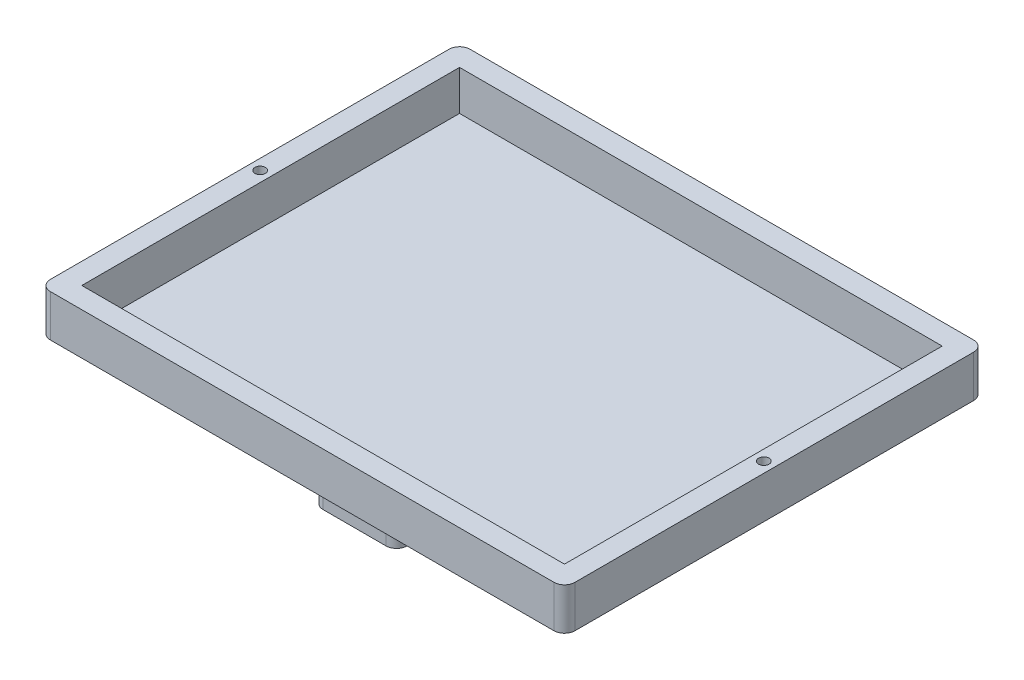
from build123d import *

# Parameters (mm, degrees)
SKETCH3_W               = 70
SKETCH3_H               = 60
BOSS_EXTRUDE1_DEPTH     = 20
BOSS_EXTRUDE2_DEPTH     = 20
SKETCH5_R               = 0.75
CUT_EXTRUDE1_DEPTH      = 119.321595662
SKETCH7_R               = 0.75
CUT_EXTRUDE2_DEPTH      = 119.321595662
LPATTERN2_COUNT         = 3
LPATTERN2_PITCH         = 2
LPATTERN3_COUNT         = 3
LPATTERN3_PITCH         = 2
SKETCH8_W               = 250
SKETCH8_H               = 200
BOSS_EXTRUDE3_DEPTH     = 20
SKETCH9_W               = 230
SKETCH9_H               = 180
CUT_EXTRUDE3_DEPTH      = 19
SKETCH10_W              = 40
SKETCH10_H              = 40
BOSS_EXTRUDE4_DEPTH     = 30
SKETCH11_W              = 34
SKETCH11_H              = 34
CUT_EXTRUDE4_DEPTH      = 28.5
SKETCH19_W              = 5
SKETCH19_H              = 5
BOSS_EXTRUDE5_DEPTH     = 10
MIRROR2_COPY_1_SKETCH_W = 5
MIRROR2_COPY_1_SKETCH_H = 5
MIRROR2_COPY_1_DEPTH    = 10
MIRROR2_COPY_3_SKETCH_W = 5
MIRROR2_COPY_3_SKETCH_H = 5
MIRROR2_COPY_3_DEPTH    = 10
SKETCH23_W              = 3
SKETCH23_H              = 3
BOSS_EXTRUDE6_DEPTH     = 28.5
MIRROR4_COPY_1_SKETCH_W = 3
MIRROR4_COPY_1_SKETCH_H = 3
MIRROR4_COPY_1_DEPTH    = 28.5
MIRROR4_COPY_2_SKETCH_W = 3
MIRROR4_COPY_2_SKETCH_H = 3
MIRROR4_COPY_2_DEPTH    = 28.5
SKETCH27_R              = 3
CUT_EXTRUDE5_DEPTH      = 199.808953521
SKETCH28_R              = 2.5
CUT_EXTRUDE6_DEPTH      = 4
SKETCH29_R              = 0.225
CUT_EXTRUDE7_DEPTH      = 209.508992612
SKETCH30_R              = 0.225
CUT_EXTRUDE8_DEPTH      = 209.508992612
FILLET1_R               = 5
FILLET2_R               = 5


with BuildPart() as part:
    # Sketch3 → Boss-Extrude1 (new body)
    with BuildSketch(Plane.XY):
        with Locations((35, 30)):
            Rectangle(SKETCH3_W, SKETCH3_H)
    extrude(amount=BOSS_EXTRUDE1_DEPTH)

    # Sketch4 → Boss-Extrude2 (add)
    with BuildSketch(Plane.XY):
        with BuildLine():
            Line((0, 60), (0, 0))
            ThreePointArc((0, 0), (-30, 30), (0, 60))
        make_face()
        with BuildLine():
            Line((70, 60), (70, 0))
            ThreePointArc((70, 0), (100, 30), (70, 60))
        make_face()
    extrude(amount=BOSS_EXTRUDE2_DEPTH)

    # Sketch5 → Cut-Extrude1 (cut, through all)
    with BuildSketch(Plane.XY):
        with Locations((20.25, 30)):
            Circle(SKETCH5_R)
    cut_extrude1 = extrude(amount=CUT_EXTRUDE1_DEPTH, mode=Mode.SUBTRACT)

    # Sketch7 → Cut-Extrude2 (cut, through all)
    with BuildSketch(Plane.XY.offset(20)):
        with Locations((49.75, 30)):
            Circle(SKETCH7_R)
    cut_extrude2 = extrude(amount=-CUT_EXTRUDE2_DEPTH, mode=Mode.SUBTRACT)

    # LPattern2: Cut-Extrude1 ×3
    with Locations(*[(i * LPATTERN2_PITCH, 0, 0) for i in range(1, LPATTERN2_COUNT)]):
        add(cut_extrude1, mode=Mode.SUBTRACT)

    # LPattern3: Cut-Extrude2 ×3
    with Locations(*[(-i * LPATTERN3_PITCH, 0, 0) for i in range(1, LPATTERN3_COUNT)]):
        add(cut_extrude2, mode=Mode.SUBTRACT)

    # Sketch8 → Boss-Extrude3 (add)
    with BuildSketch(Plane(origin=(0, 60, 0), x_dir=(1, 0, 0), z_dir=(0, 1, 0))):
        with Locations((35, -10)):
            Rectangle(SKETCH8_W, SKETCH8_H)
    extrude(amount=BOSS_EXTRUDE3_DEPTH)

    # Sketch9 → Cut-Extrude3 (cut)
    with BuildSketch(Plane(origin=(0, 80, 0), x_dir=(1, 0, 0), z_dir=(0, 1, 0))):
        with Locations((35, -10)):
            Rectangle(SKETCH9_W, SKETCH9_H)
    extrude(amount=-CUT_EXTRUDE3_DEPTH, mode=Mode.SUBTRACT)

    # Sketch10 → Boss-Extrude4 (add)
    with BuildSketch(Plane.XZ.offset(-60)):
        with Locations((35, 65)):
            Rectangle(SKETCH10_W, SKETCH10_H)
    extrude(amount=BOSS_EXTRUDE4_DEPTH)

    # Sketch11 → Cut-Extrude4 (cut)
    with BuildSketch(Plane.XZ.offset(-30)):
        with Locations((35, 65)):
            Rectangle(SKETCH11_W, SKETCH11_H)
    extrude(amount=-CUT_EXTRUDE4_DEPTH, mode=Mode.SUBTRACT)

    # Sketch19 → Boss-Extrude5 (add)
    with BuildSketch(Plane.XZ.offset(-58.5)):
        with Locations((25.055, 74.81)):
            Rectangle(SKETCH19_W, SKETCH19_H)
    boss_extrude5 = extrude(amount=BOSS_EXTRUDE5_DEPTH)

    # Sketch22 → Ø3.0mm Dowel Hole1 (revolve, cut)
    with BuildSketch(Plane(origin=(23.755, 48.5, 76.11), x_dir=(0, 0, -1), z_dir=(1, 0, 0))):
        Polygon((0, 0), (0, 10.457855792), (0.762, 10), (0.762, 0), align=None)
    f_3_0mm_dowel_hole1 = revolve(axis=Axis((23.755, 42.15, 76.11), (0, 1, 0)), mode=Mode.SUBTRACT)

    # Mirror1: Boss-Extrude5, Ø3.0mm Dowel Hole1 across plane
    add(boss_extrude5.mirror(Plane(origin=(35, 0, 0), x_dir=(0, 0, 1), z_dir=(1, 0, 0))))
    add(f_3_0mm_dowel_hole1.mirror(Plane(origin=(35, 0, 0), x_dir=(0, 0, 1), z_dir=(1, 0, 0))), mode=Mode.SUBTRACT)

    # Mirror2 copy 1 sketch → Mirror2 copy 1 (add)
    with BuildSketch(Plane(origin=(70, 58.5, 130), x_dir=(-1, 0, 0), z_dir=(0, -1, 0))):
        with Locations((25.055, 74.81)):
            Rectangle(MIRROR2_COPY_1_SKETCH_W, MIRROR2_COPY_1_SKETCH_H)
    extrude(amount=MIRROR2_COPY_1_DEPTH)

    # Mirror2 copy 2 sketch → Mirror2 copy 2 (revolve, cut)
    with BuildSketch(Plane(origin=(46.245, 48.5, 53.89), x_dir=(0, 0, 1), z_dir=(-1, 0, 0))):
        Polygon((0, 0), (0, 10.457855792), (0.762, 10), (0.762, 0), align=None)
    revolve(axis=Axis((46.245, 42.15, 53.89), (0, 1, 0)), mode=Mode.SUBTRACT)

    # Mirror2 copy 3 sketch → Mirror2 copy 3 (add)
    with BuildSketch(Plane(origin=(0, 58.5, 130), x_dir=(1, 0, 0), z_dir=(0, -1, 0))):
        with Locations((25.055, -74.81)):
            Rectangle(MIRROR2_COPY_3_SKETCH_W, MIRROR2_COPY_3_SKETCH_H)
    extrude(amount=MIRROR2_COPY_3_DEPTH)

    # Mirror2 copy 4 sketch → Mirror2 copy 4 (revolve, cut)
    with BuildSketch(Plane(origin=(23.755, 48.5, 53.89), x_dir=(0, 0, 1), z_dir=(1, 0, 0))):
        Polygon((0, 0), (0, -10.457855792), (0.762, -10), (0.762, 0), align=None)
    revolve(axis=Axis((23.755, 42.15, 53.89), (0, -1, 0)), mode=Mode.SUBTRACT)

    # Sketch23 → Boss-Extrude6 (add)
    with BuildSketch(Plane.XZ.offset(-58.5)):
        with Locations((19.5, 80.5)):
            Rectangle(SKETCH23_W, SKETCH23_H)
    boss_extrude6 = extrude(amount=BOSS_EXTRUDE6_DEPTH)

    # Mirror3: Boss-Extrude6 across plane
    add(boss_extrude6.mirror(Plane.XY.offset(65)))

    # Mirror4 copy 1 sketch → Mirror4 copy 1 (add)
    with BuildSketch(Plane(origin=(70, 58.5, 130), x_dir=(-1, 0, 0), z_dir=(0, -1, 0))):
        with Locations((19.5, 80.5)):
            Rectangle(MIRROR4_COPY_1_SKETCH_W, MIRROR4_COPY_1_SKETCH_H)
    extrude(amount=MIRROR4_COPY_1_DEPTH)

    # Mirror4 copy 2 sketch → Mirror4 copy 2 (add)
    with BuildSketch(Plane(origin=(70, 58.5, 0), x_dir=(-1, 0, 0), z_dir=(0, -1, 0))):
        with Locations((19.5, -80.5)):
            Rectangle(MIRROR4_COPY_2_SKETCH_W, MIRROR4_COPY_2_SKETCH_H)
    extrude(amount=MIRROR4_COPY_2_DEPTH)

    # Sketch26 → Ø3.0mm Dowel Hole2 (revolve, cut)
    with BuildSketch(Plane(origin=(18, 30, 82), x_dir=(0, 0, -1), z_dir=(1, 0, 0))):
        Polygon((0, 0), (0, 10.901290929), (1.5, 10), (1.5, 0), align=None)
    f_3_0mm_dowel_hole2 = revolve(axis=Axis((18, 23.65, 82), (0, 1, 0)), mode=Mode.SUBTRACT)

    # Mirror5: Ø3.0mm Dowel Hole2 across plane
    add(f_3_0mm_dowel_hole2.mirror(Plane.XY.offset(65)), mode=Mode.SUBTRACT)

    # Mirror6 copy 1 sketch → Mirror6 copy 1 (revolve, cut)
    with BuildSketch(Plane(origin=(52, 30, 48), x_dir=(0, 0, 1), z_dir=(-1, 0, 0))):
        Polygon((0, 0), (0, 10.901290929), (1.5, 10), (1.5, 0), align=None)
    revolve(axis=Axis((52, 23.65, 48), (0, 1, 0)), mode=Mode.SUBTRACT)

    # Mirror6 copy 2 sketch → Mirror6 copy 2 (revolve, cut)
    with BuildSketch(Plane(origin=(52, 30, 82), x_dir=(0, 0, -1), z_dir=(-1, 0, 0))):
        Polygon((0, 0), (0, -10.901290929), (1.5, -10), (1.5, 0), align=None)
    revolve(axis=Axis((52, 23.65, 82), (0, -1, 0)), mode=Mode.SUBTRACT)

    # Sketch27 → Cut-Extrude5 (cut, through all)
    with BuildSketch(Plane(origin=(55, 0, 0), x_dir=(0, 0, -1), z_dir=(1, 0, 0))):
        with Locations((-65, 40)):
            Circle(SKETCH27_R)
    extrude(amount=-CUT_EXTRUDE5_DEPTH, mode=Mode.SUBTRACT)

    # Sketch28 → Cut-Extrude6 (cut)
    with BuildSketch(Plane(origin=(0, 80, 0), x_dir=(1, 0, 0), z_dir=(0, 1, 0))):
        with Locations((-85, -10)):
            Circle(SKETCH28_R)
    cut_extrude6 = extrude(amount=-CUT_EXTRUDE6_DEPTH, mode=Mode.SUBTRACT)

    # Sketch29 → Cut-Extrude7 (cut, through all)
    with BuildSketch(Plane(origin=(0, 76, 0), x_dir=(1, 0, 0), z_dir=(0, 1, 0))):
        with Locations((-85, -8.3)):
            Circle(SKETCH29_R)
    cut_extrude7 = extrude(amount=-CUT_EXTRUDE7_DEPTH, mode=Mode.SUBTRACT)

    # Sketch30 → Cut-Extrude8 (cut, through all)
    with BuildSketch(Plane(origin=(0, 76, 0), x_dir=(1, 0, 0), z_dir=(0, 1, 0))):
        with Locations((-85, -11.7)):
            Circle(SKETCH30_R)
    cut_extrude8 = extrude(amount=-CUT_EXTRUDE8_DEPTH, mode=Mode.SUBTRACT)

    # Mirror7: Cut-Extrude6, Cut-Extrude7, Cut-Extrude8 across plane
    add(cut_extrude6.mirror(Plane.ZY.offset(-35)), mode=Mode.SUBTRACT)
    add(cut_extrude7.mirror(Plane.ZY.offset(-35)), mode=Mode.SUBTRACT)
    add(cut_extrude8.mirror(Plane.ZY.offset(-35)), mode=Mode.SUBTRACT)

    # Fillet1
    fillet1_edges = [part.edges().sort_by_distance(p)[0] for p in [
        (-90, 70, -90),
        (-90, 70, 110),
        (160, 70, 110),
        (160, 70, -90),
    ]]
    fillet(fillet1_edges, radius=FILLET1_R)

    # Fillet2
    fillet2_edges = [part.edges().sort_by_distance(p)[0] for p in [
        (55, 45, 45),
        (55, 45, 85),
        (15, 45, 45),
        (15, 45, 85),
    ]]
    fillet(fillet2_edges, radius=FILLET2_R)


solid = part.part
